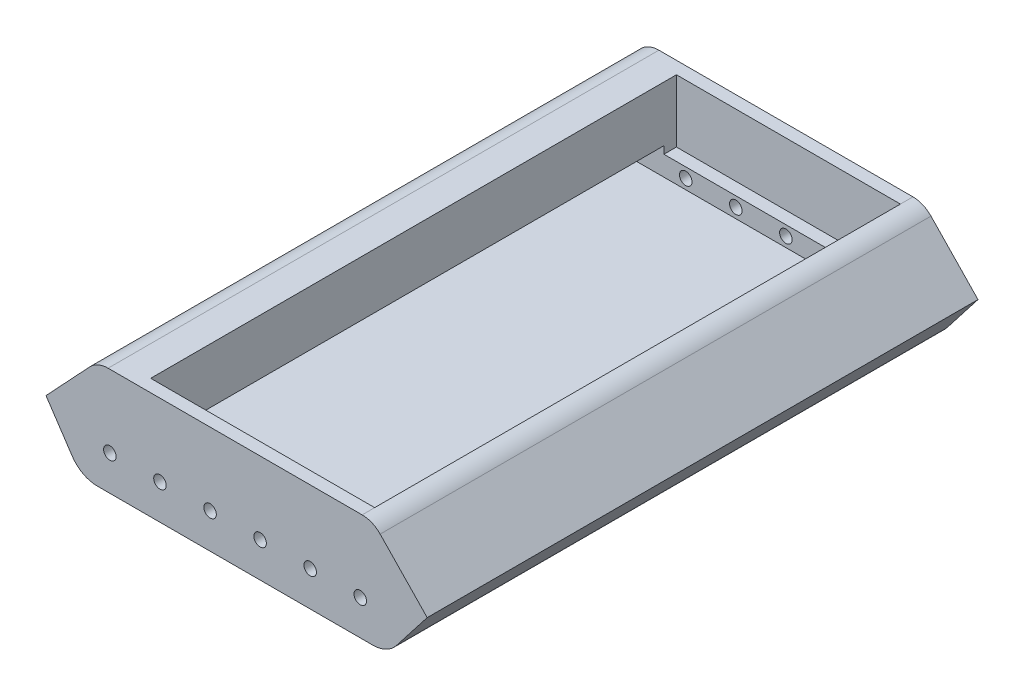
from build123d import *

# Parameters (mm, degrees)
EXTRUDE_THIN1_DEPTH = 220
BOSS_EXTRUDE1_DEPTH = 10
BOSS_EXTRUDE2_DEPTH = 10
CUT_EXTRUDE1_DEPTH  = 221
SKETCH6_R           = 2.5
CUT_EXTRUDE3_DEPTH  = 221
BOSS_EXTRUDE3_DEPTH = 220
SKETCH9_W           = 89.464875501
SKETCH9_H           = 210
CUT_EXTRUDE5_DEPTH  = 25
SKETCH10_W          = 38.507874252
SKETCH10_H          = 15.616205768
CUT_EXTRUDE6_DEPTH  = 20


with BuildPart() as part:
    # Sketch1 → Extrude-Thin1 (new body)
    with BuildSketch(Plane.XY):
        with BuildLine():
            Line((-111.804811095, -25.936023273), (-1.752290831, -25.936023273))
            ThreePointArc((-1.752290831, -25.936023273), (3.519458689, -24.716035193), (7.71929628, -21.304132772))
            Line((7.71929628, -21.304132772), (21.420171512, -3.691876429))
            Line((21.420171512, -3.691876429), (8.721276915, 5.936816741))
            ThreePointArc((8.721276915, 5.936816741), (3.01180177, 8.957008398), (-3.362508592, 10))
            Line((-3.362508592, 10), (-109.847422235, 10))
            ThreePointArc((-109.847422235, 10), (-115.643105208, 9.14184053), (-120.941426159, 6.641005887))
            Line((-120.941426159, 6.641005887), (-134.097771182, -2.129890795))
            Line((-134.097771182, -2.129890795), (-121.789414627, -20.592425628))
            ThreePointArc((-121.789414627, -20.592425628), (-117.467106201, -24.516118458), (-111.804811095, -25.936023273))
        make_face()
        with BuildLine():
            Line((-111.804811095, -15.936023273), (-1.752290831, -15.936023273))
            ThreePointArc((-1.752290831, -15.936023273), (-0.873665911, -15.732691927), (-0.17369298, -15.164041523))
            Line((-0.17369298, -15.164041523), (7.310590323, -5.543114841))
            Line((7.310590323, -5.543114841), (2.679384161, -2.03159163))
            ThreePointArc((2.679384161, -2.03159163), (-0.175353411, -0.521495801), (-3.362508592, 0))
            Line((-3.362508592, 0), (-109.847422235, 0))
            ThreePointArc((-109.847422235, 0), (-112.745263722, -0.429079735), (-115.394424197, -1.679497057))
            Line((-115.394424197, -1.679497057), (-120.230266277, -4.903391776))
            Line((-120.230266277, -4.903391776), (-113.468911684, -15.045423666))
            ThreePointArc((-113.468911684, -15.045423666), (-112.748526946, -15.699372471), (-111.804811095, -15.936023273))
        make_face(mode=Mode.SUBTRACT)
    extrude(amount=EXTRUDE_THIN1_DEPTH)

    # Sketch3 → Boss-Extrude1 (add)
    with BuildSketch(Plane.XY.offset(220)):
        Polygon((-120.230266277, -4.903391776), (7.310590323, -5.543114841), (7.310590323, -21.801402169), (-120.525433927, -22.179247), align=None)
    extrude(amount=-BOSS_EXTRUDE1_DEPTH)

    # Sketch4 → Boss-Extrude2 (add)
    with BuildSketch(Plane(origin=(0, 0, 0), x_dir=(-1, 0, 0), z_dir=(0, 0, -1))):
        Polygon((-7.310590323, -5.543114841), (120.230266277, -4.903391776), (120.230266277, -22.480711973), (-5.288915881, -22.480711973), (-7.235397459, -20.534230396), align=None)
    extrude(amount=-BOSS_EXTRUDE2_DEPTH)

    # Sketch5 → Cut-Extrude1 (cut, through all)
    with BuildSketch(Plane(origin=(0, 0, 0), x_dir=(-1, 0, 0), z_dir=(0, 0, -1))):
        Polygon((-7.310590323, -5.543114841), (-30.090389748, -5.543114841), (-30.090389748, 22.160064079), (140.461111039, 22.160064079), (140.461111039, -4.844552144), (120.230266277, -4.903391776), align=None)
    extrude(amount=-CUT_EXTRUDE1_DEPTH, mode=Mode.SUBTRACT)

    # Sketch6 → Cut-Extrude3 (cut, through all)
    with BuildSketch(Plane.XY.offset(220)):
        with Locations((-106.752290831, -11.972659606)):
            Circle(SKETCH6_R)
        with Locations((-6.752290831, -11.972659606)):
            Circle(SKETCH6_R)
        with Locations((-86.752290831, -11.972659606)):
            Circle(SKETCH6_R)
        with Locations((-66.752290831, -11.972659606)):
            Circle(SKETCH6_R)
        with Locations((-46.752290831, -11.972659606)):
            Circle(SKETCH6_R)
        with Locations((-26.752290831, -11.972659606)):
            Circle(SKETCH6_R)
    extrude(amount=-CUT_EXTRUDE3_DEPTH, mode=Mode.SUBTRACT)

    # Sketch8 → Boss-Extrude3 (add)
    with BuildSketch(Plane.XY.offset(220)):
        with BuildLine():
            Line((-107.467244942, 17.002107807), (-6.002369441, 17.002107807))
            ThreePointArc((-6.002369441, 17.002107807), (-2.090901759, 16.205390949), (1.197299473, 13.942191923))
            Line((1.197299473, 13.942191923), (19.98006151, -5.543114841))
            Line((19.98006151, -5.543114841), (7.310590323, -5.543114841))
            Line((7.310590323, -5.543114841), (-120.230266277, -4.903391776))
            Line((-120.230266277, -4.903391776), (-132.272118974, -4.868369107))
            Line((-132.272118974, -4.868369107), (-114.768654919, 13.835072929))
            ThreePointArc((-114.768654919, 13.835072929), (-111.446588404, 16.176246765), (-107.467244942, 17.002107807))
        make_face()
    extrude(amount=-BOSS_EXTRUDE3_DEPTH)

    # Sketch9 → Cut-Extrude5 (cut)
    with BuildSketch(Plane(origin=(0, 17.002107807, 0), x_dir=(1, 0, 0), z_dir=(0, 1, 0))):
        with Locations((-50.734807192, -110)):
            Rectangle(SKETCH9_W, SKETCH9_H)
    extrude(amount=-CUT_EXTRUDE5_DEPTH, mode=Mode.SUBTRACT)

    # Sketch10 → Cut-Extrude6 (cut)
    with BuildSketch(Plane(origin=(-68.086200957, 63.717917206, 0), x_dir=(0, 0, 1), z_dir=(-0.730140998, 0.683296512, 0))):
        with Locations((110, -82.127570542)):
            Rectangle(SKETCH10_W, SKETCH10_H)
    extrude(amount=-CUT_EXTRUDE6_DEPTH, mode=Mode.SUBTRACT)


solid = part.part
